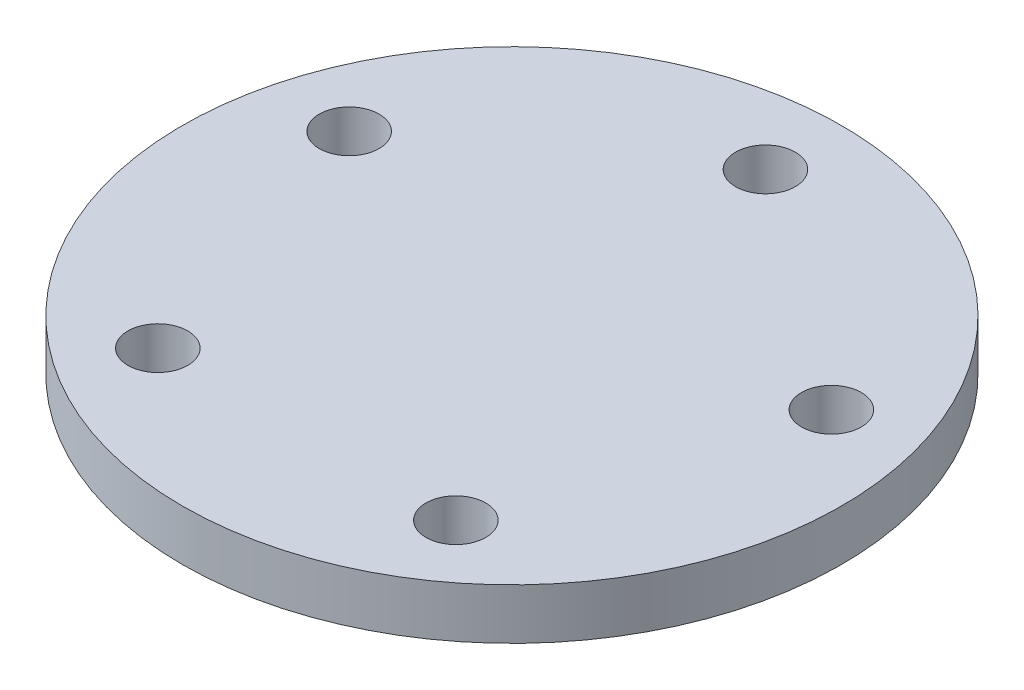
from build123d import *

# Parameters (mm, degrees)
SKETCH1_R           = 17.5
BOSS_EXTRUDE1_DEPTH = 10
SKETCH2_R           = 32.5
BOSS_EXTRUDE2_DEPTH = 5
SKETCH3_R           = 2.95
CUT_EXTRUDE1_DEPTH  = 7


with BuildPart() as part:
    # Sketch1 → Boss-Extrude1 (new body)
    with BuildSketch(Plane(origin=(0, 0, 0), x_dir=(1, 0, 0), z_dir=(0, 1, 0))):
        Circle(SKETCH1_R)
    extrude(amount=BOSS_EXTRUDE1_DEPTH)

    # Sketch2 → Boss-Extrude2 (add)
    with BuildSketch(Plane(origin=(0, 10, 0), x_dir=(1, 0, 0), z_dir=(0, 1, 0))):
        Circle(SKETCH2_R)
    extrude(amount=BOSS_EXTRUDE2_DEPTH)

    # Sketch3 → Cut-Extrude1 (cut)
    with BuildSketch(Plane(origin=(0, 15, 0), x_dir=(1, 0, 0), z_dir=(0, 1, 0))):
        with Locations((0, 25)):
            Circle(SKETCH3_R)
        with Locations((23.776412907, 7.725424859)):
            Circle(SKETCH3_R)
        with Locations((14.694631307, -20.225424859)):
            Circle(SKETCH3_R)
        with Locations((-14.694631307, -20.225424859)):
            Circle(SKETCH3_R)
        with Locations((-23.776412907, 7.725424859)):
            Circle(SKETCH3_R)
    extrude(amount=-CUT_EXTRUDE1_DEPTH, mode=Mode.SUBTRACT)


solid = part.part
